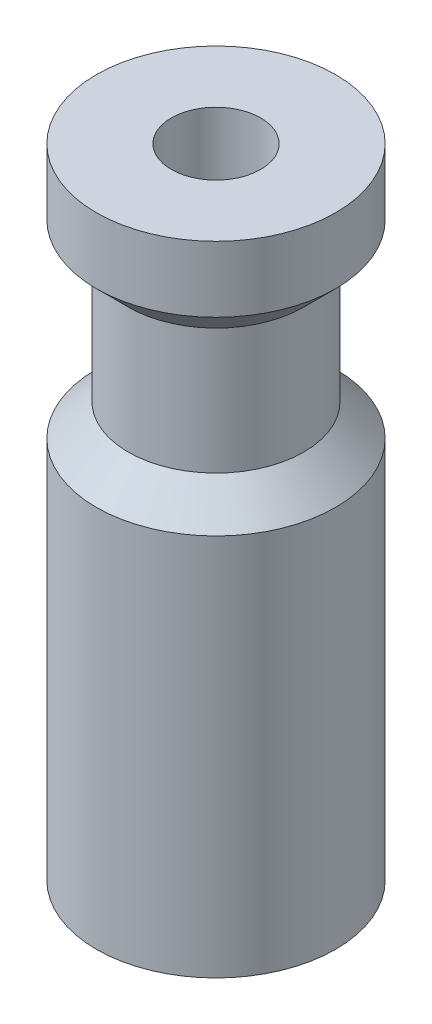
from build123d import *

# Parameters (mm, degrees)
SKETCH3_R          = 1.778
CUT_EXTRUDE1_DEPTH = 27.94


with BuildPart() as part:
    # Sketch2 → Revolve1 (revolve)
    with BuildSketch(Plane.XY):
        Polygon((0, 12.7), (0, -12.7), (4.7625, -12.7), (4.7625, 2.54), (3.4925, 3.81), (3.4925, 8.81), (4.7625, 10.08), (4.7625, 12.7), align=None)
    revolve(axis=Axis((0, 12.7, 0), (0, -1, 0)))

    # Sketch3 → Cut-Extrude1 (cut)
    with BuildSketch(Plane(origin=(0, 12.7, 0), x_dir=(1, 0, 0), z_dir=(0, 1, 0))):
        Circle(SKETCH3_R)
    extrude(amount=-CUT_EXTRUDE1_DEPTH, mode=Mode.SUBTRACT)


solid = part.part
